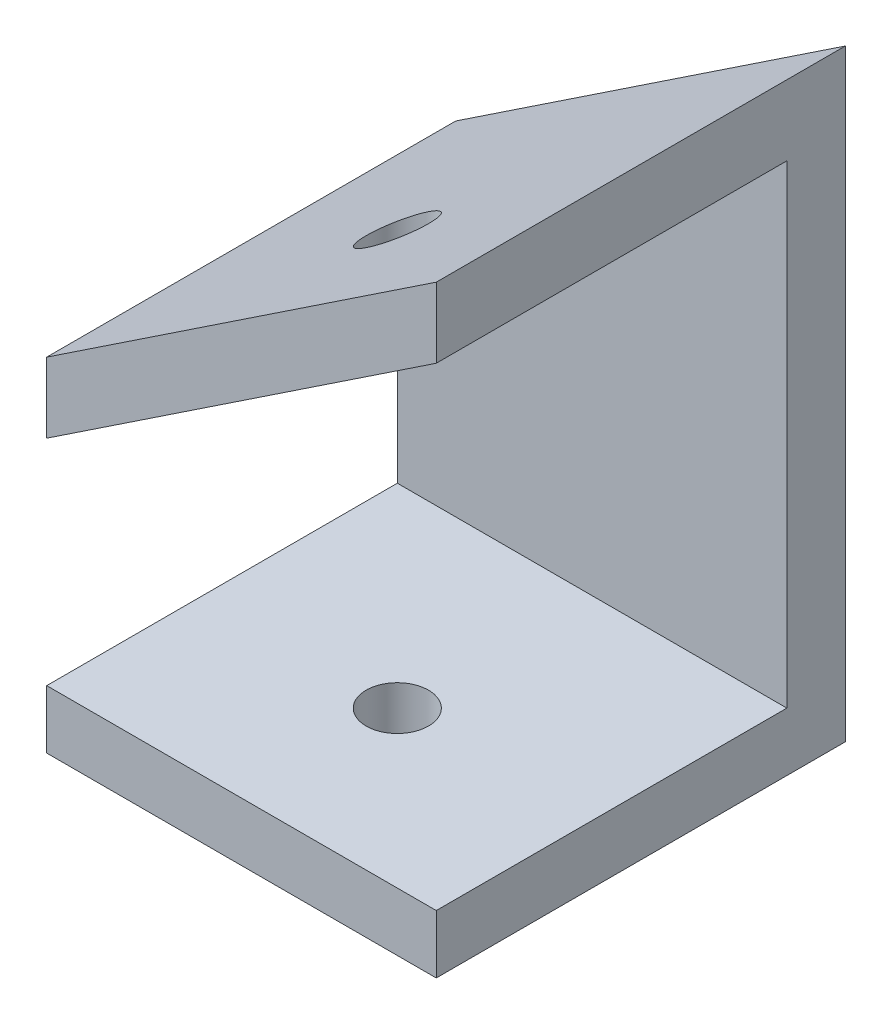
from build123d import *

# Parameters (mm, degrees)
EXTRUDE_1_DEPTH      = 3
SKETCH_2_W           = 20
SKETCH_2_H           = 3
EXTRUDE_2_DEPTH      = 18
EXTRUDE_2_DEPTH_BACK = 3
SKETCH_5_R           = 1.6
CUT_EXTRUDE_1_DEPTH  = 31.938884609


with BuildPart() as part:
    # 草图1 → 凸台-拉伸1 (new body)
    with BuildSketch(Plane.XY):
        Polygon((-7.634327041, -2.906141593), (-7.634327041, 8.093858407), (12.365672959, 21.427191741), (12.365672959, -5.906141593), (-7.634327041, -5.906141593), align=None)
    extrude(amount=EXTRUDE_1_DEPTH)

    # 草图2 → 凸台-拉伸2 (add, two sides)
    with BuildSketch(Plane.XY.offset(3)) as extrude_2_sk:
        Polygon((-7.634327041, 8.093858407), (12.365672959, 21.427191741), (12.365672959, 25.032743016), (-7.634327041, 11.699409683), align=None)
        with Locations((2.365672959, -4.406141593)):
            Rectangle(SKETCH_2_W, SKETCH_2_H)
    extrude(amount=EXTRUDE_2_DEPTH)
    extrude(extrude_2_sk.sketch, amount=-EXTRUDE_2_DEPTH_BACK)

    # 草图5 → 切除-拉伸1 (cut, through all)
    with BuildSketch(Plane.XZ.offset(5.906141593)):
        with Locations((2.365672959, 13)):
            Circle(SKETCH_5_R)
    extrude(amount=-CUT_EXTRUDE_1_DEPTH, mode=Mode.SUBTRACT)


solid = part.part
